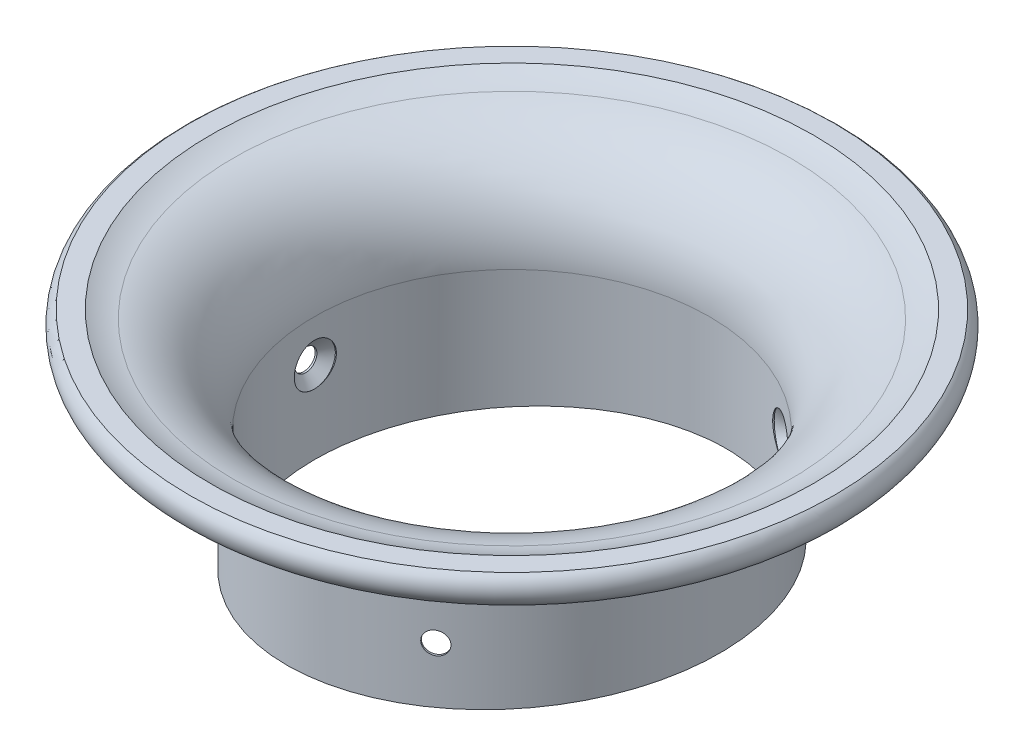
from build123d import *

# Parameters (mm, degrees)
CUT_EXTRUDE1_DEPTH                                  = 198.511547075
CUT_EXTRUDE1_DEPTH_BACK                             = 198.511547075
CSK_FOR_1_4_FLAT_HEAD_MACHINE_SCREW_100_D           = 6.7564
CSK_FOR_1_4_FLAT_HEAD_MACHINE_SCREW_100_DEPTH       = 26.418979166
CSK_FOR_1_4_FLAT_HEAD_MACHINE_SCREW_100_CSINK_D     = 12.8778
CSK_FOR_1_4_FLAT_HEAD_MACHINE_SCREW_100_CSINK_ANGLE = 100
CIRPATTERN1_COUNT                                   = 3
FILLET1_R                                           = 25.4
SKETCH6_W                                           = 228.6
SKETCH6_H                                           = 42.39695855
CUT_EXTRUDE2_DEPTH                                  = 198.511547094
CUT_EXTRUDE2_DEPTH_BACK                             = 198.511547094


with BuildPart() as part:
    # Sketch2 → RevolvedVenturi-5inchOutsideDiaLower_2inchDeep (revolve)
    with BuildSketch(Plane.XY, mode=Mode.PRIVATE) as revolvedventuri_5inchoutsidedialower_2in_sk:
        with BuildLine():
            Line((0, 0), (1.5875, 0))
            Line((1.5875, 0), (1.5875, -38.1))
            Line((1.5875, -38.1), (4.7625, -38.1))
            Line((4.7625, -38.1), (4.7625, 0))
            ThreePointArc((4.7625, 0), (-4.071891712, 21.328108288), (-25.4, 30.1625))
            ThreePointArc((-25.4, 30.1625), (-35.487136871, 27.78125), (-25.4, 25.4))
            ThreePointArc((-25.4, 25.4), (-7.439487758, 17.960512242), (0, 0))
        make_face()
    revolve(revolvedventuri_5inchoutsidedialower_2in_sk.sketch.rotate(Axis((65.0875, -38.1, 0), (0, 1, 0)), 270), axis=Axis((65.0875, -38.1, 0), (0, 1, 0)))

    # Sketch3 → Cut-Extrude1 (cut, two sides)
    with BuildSketch(Plane.XY) as cut_extrude1_sk:
        Polygon((305.270582806, -11.53117295), (1.5875, -38.1), (5.893342851, -87.316008998), (309.576425657, -60.747181948), align=None)
    extrude(amount=CUT_EXTRUDE1_DEPTH, mode=Mode.SUBTRACT)
    extrude(cut_extrude1_sk.sketch, amount=-CUT_EXTRUDE1_DEPTH_BACK, mode=Mode.SUBTRACT)

    # CSK for 1/4 Flat Head Machine Screw (100)1
    with Locations(Plane(origin=(4.7625, -12.7, 0), x_dir=(0, 0, 1), z_dir=(1, 0, 0))):
        with Locations((0, 0)):
            csk_for_1_4_flat_head_machine_screw_100 = CounterSinkHole(CSK_FOR_1_4_FLAT_HEAD_MACHINE_SCREW_100_D / 2, CSK_FOR_1_4_FLAT_HEAD_MACHINE_SCREW_100_CSINK_D / 2, depth=CSK_FOR_1_4_FLAT_HEAD_MACHINE_SCREW_100_DEPTH, counter_sink_angle=CSK_FOR_1_4_FLAT_HEAD_MACHINE_SCREW_100_CSINK_ANGLE)

    # CirPattern1: CSK for 1/4 Flat Head Machine Screw (100)1 ×3 about axis
    cirpattern1_axis = Axis((65.0875, 0, 0), (0, -1, 0))
    for i in range(1, CIRPATTERN1_COUNT):
        add(csk_for_1_4_flat_head_machine_screw_100.rotate(cirpattern1_axis, i * 360 / CIRPATTERN1_COUNT), mode=Mode.SUBTRACT)

    # Fillet1
    fillet1_edges = [part.edges().sort_by_distance(p)[0] for p in [
        (65.0875, 30.1625, 90.4875),
    ]]
    fillet(fillet1_edges, radius=FILLET1_R)

    # Sketch6 → Cut-Extrude2 (cut, two sides)
    with BuildSketch(Plane.XY) as cut_extrude2_sk:
        with Locations((69.663229711, 53.30825)):
            Rectangle(SKETCH6_W, SKETCH6_H)
    extrude(amount=CUT_EXTRUDE2_DEPTH, mode=Mode.SUBTRACT)
    extrude(cut_extrude2_sk.sketch, amount=-CUT_EXTRUDE2_DEPTH_BACK, mode=Mode.SUBTRACT)


solid = part.part
